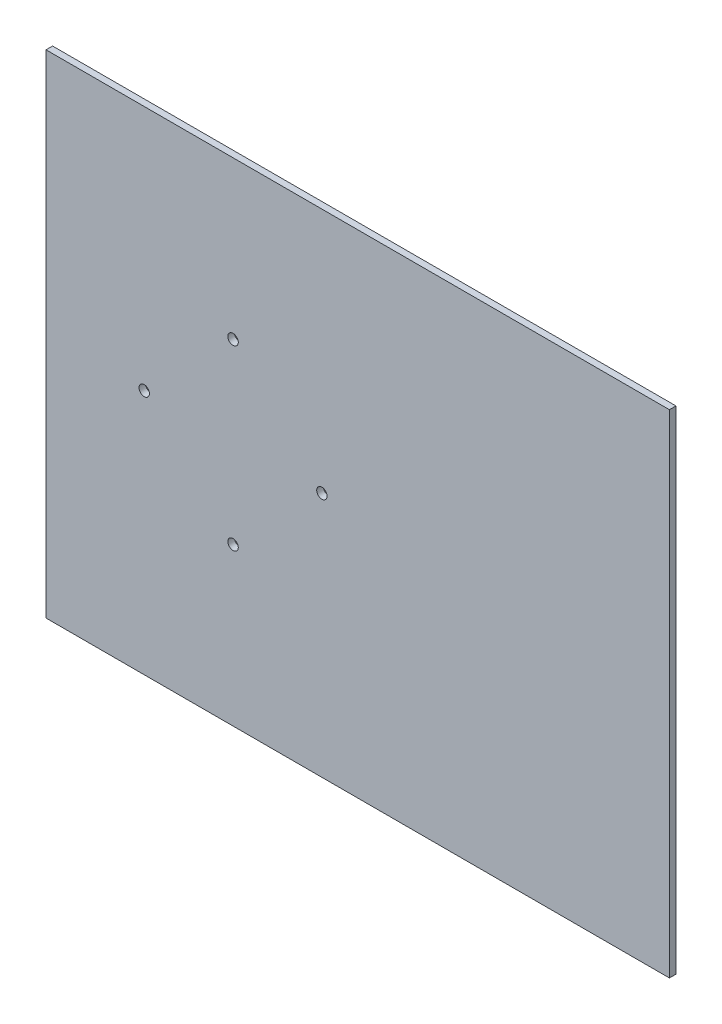
from build123d import *

# Parameters (mm, degrees)
SKETCH1_W           = 380
SKETCH1_H           = 300
BOSS_EXTRUDE1_DEPTH = 4
SKETCH7_RX          = 3.2
SKETCH7_RY          = 3.15
CUT_EXTRUDE18_DEPTH = 4


with BuildPart() as part:
    # Sketch1 → Boss-Extrude1 (new body)
    with BuildSketch(Plane.XY):
        with Locations((77.345324037, -97.095823821)):
            Rectangle(SKETCH1_W, SKETCH1_H)
    extrude(amount=BOSS_EXTRUDE1_DEPTH)

    # Sketch7 → Cut-Extrude18 (cut)
    with BuildSketch(Plane.XY.offset(4)):
        with Locations((1.345324037, -42.945823821)):
            Ellipse(SKETCH7_RX, SKETCH7_RY)
        with Locations(Location((55.495324037, -97.095823821), (0, 0, -90))):
            Ellipse(SKETCH7_RX, SKETCH7_RY)
        with Locations(Location((1.345324037, -151.245823821), (0, 0, 180))):
            Ellipse(SKETCH7_RX, SKETCH7_RY)
        with Locations(Location((-52.804675963, -97.095823821), (0, 0, -90))):
            Ellipse(SKETCH7_RX, SKETCH7_RY)
    extrude(amount=-CUT_EXTRUDE18_DEPTH, mode=Mode.SUBTRACT)


solid = part.part
